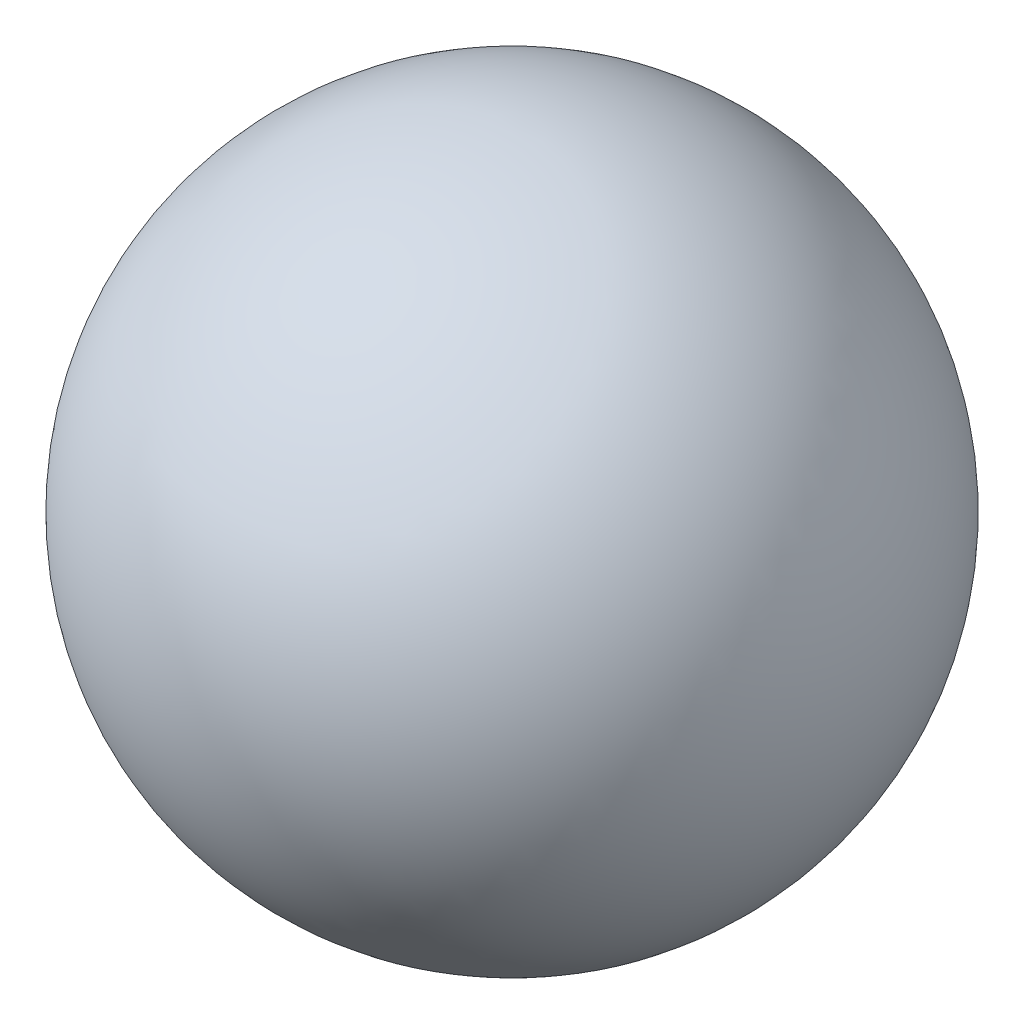
from build123d import *


with BuildPart() as part:
    # Esquisse1 → Révolution4 (revolve)
    with BuildSketch(Plane.XY):
        with BuildLine():
            Line((0, 12), (0, -12))
            ThreePointArc((0, -12), (-12, 0), (0, 12))
        make_face()
    revolve(axis=Axis((0, 12, 0), (0, -1, 0)))


solid = part.part
